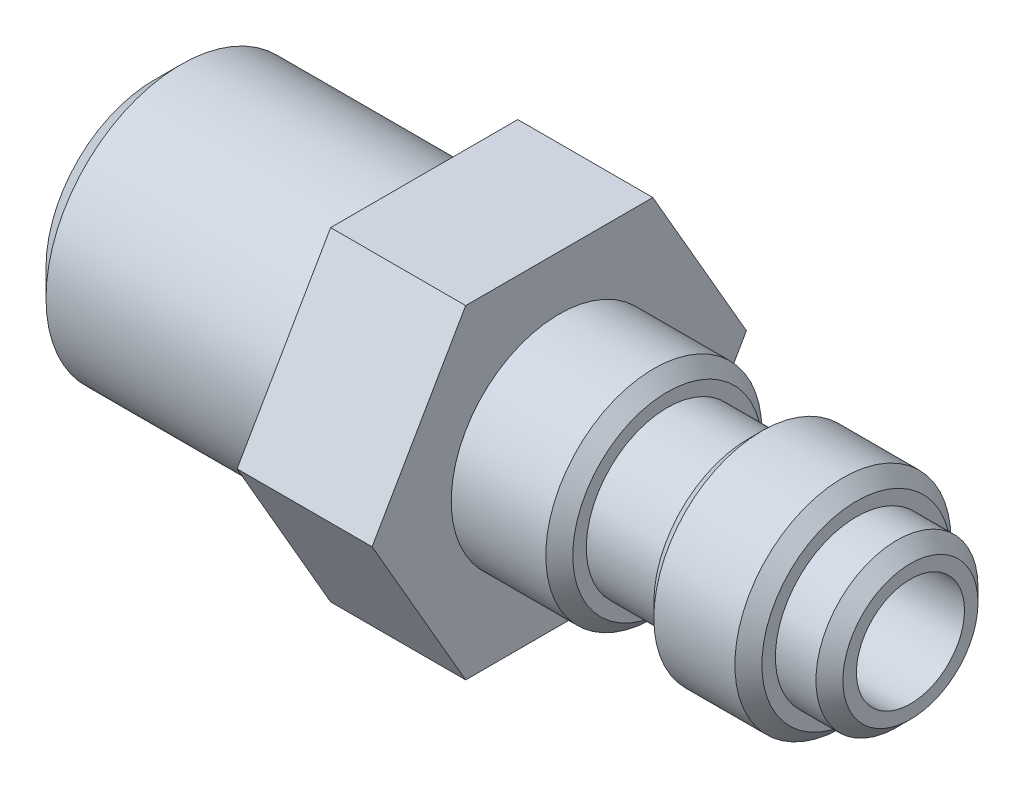
from build123d import *

# Parameters (mm, degrees)
BOSS_EXTRUDE1_DEPTH = 5
SKETCH3_R           = 5
BOSS_EXTRUDE2_DEPTH = 10
SKETCH4_R           = 2
CUT_EXTRUDE1_DEPTH  = 29
CHAMFER1_SIZE       = 0.5
CHAMFER2_SIZE       = 1


with BuildPart() as part:
    # Sketch1 → Revolve1 (revolve)
    with BuildSketch(Plane(origin=(0, 0, 0), x_dir=(1, 0, 0), z_dir=(0, 1, 0))):
        Polygon((0, 0), (0, 3), (-2, 3), (-2, 4), (-6, 4), (-6, 3), (-9, 3), (-9, 4), (-13, 4), (-13, 0), align=None)
    revolve(axis=Axis((8.879781421, 0, 0), (-1, 0, 0)))

    # Sketch2 → Boss-Extrude1 (add)
    with BuildSketch(Plane.ZY.offset(13)):
        Polygon((6.92820323, 0), (3.464101615, 6), (-3.464101615, 6), (-6.92820323, 0), (-3.464101615, -6), (3.464101615, -6), align=None)
    extrude(amount=BOSS_EXTRUDE1_DEPTH)

    # Sketch3 → Boss-Extrude2 (add)
    with BuildSketch(Plane.ZY.offset(18)):
        Circle(SKETCH3_R)
    extrude(amount=BOSS_EXTRUDE2_DEPTH)

    # Sketch4 → Cut-Extrude1 (cut, through all)
    with BuildSketch(Plane(origin=(0, 0, 0), x_dir=(0, 0, -1), z_dir=(1, 0, 0))):
        Circle(SKETCH4_R)
    extrude(amount=-CUT_EXTRUDE1_DEPTH, mode=Mode.SUBTRACT)

    # Chamfer1
    chamfer1_edges = [part.edges().sort_by_distance(p)[0] for p in [
        (-6, 0, 4),
        (-2, 0, 4),
        (0, 0, 3),
        (-28, 0, 2),
        (-9, 0, 4),
    ]]
    chamfer(chamfer1_edges, length=CHAMFER1_SIZE)

    # Chamfer2
    chamfer2_edges = [part.edges().sort_by_distance(p)[0] for p in [
        (-28, 0, -5),
    ]]
    chamfer(chamfer2_edges, length=CHAMFER2_SIZE)


solid = part.part
